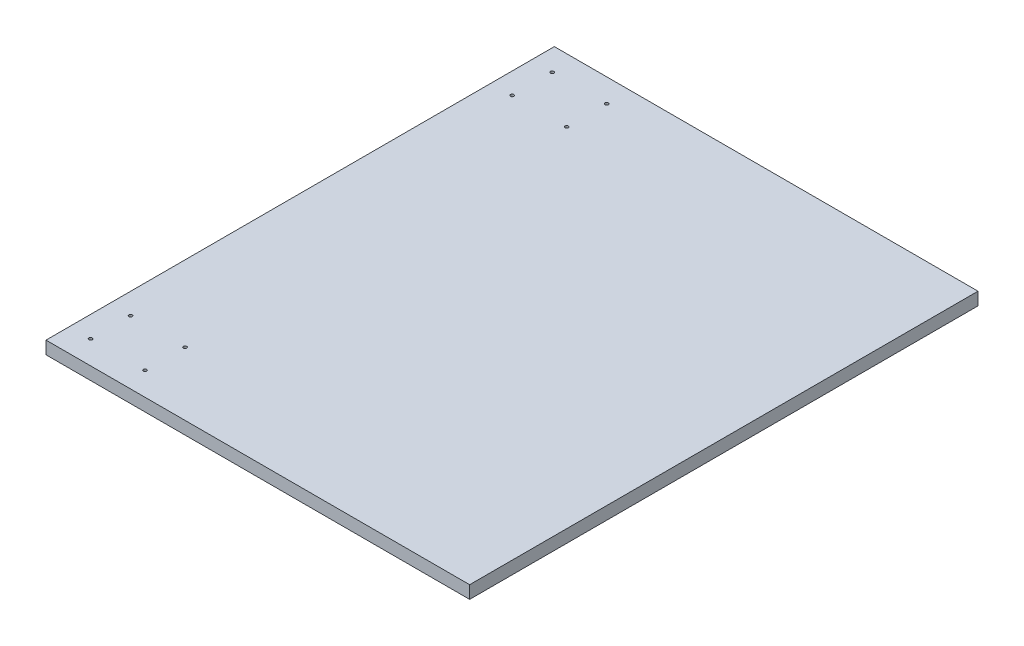
from build123d import *

# Parameters (mm, degrees)
SKETCH1_W           = 381
SKETCH1_H           = 457.2
BOSS_EXTRUDE1_DEPTH = 11.4554
SKETCH3_R           = 1.5
CUT_EXTRUDE1_DEPTH  = 12.4554


with BuildPart() as part:
    # Sketch1 → Boss-Extrude1 (new body)
    with BuildSketch(Plane(origin=(0, 0, 0), x_dir=(1, 0, 0), z_dir=(0, 1, 0))):
        Rectangle(SKETCH1_W, SKETCH1_H)
    extrude(amount=BOSS_EXTRUDE1_DEPTH)

    # Sketch3 → Cut-Extrude1 (cut, through all)
    with BuildSketch(Plane(origin=(0, 11.4554, 0), x_dir=(1, 0, 0), z_dir=(0, 1, 0))):
        with Locations((-122.45, 207.6)):
            Circle(SKETCH3_R)
        with Locations((-171.45, 207.6)):
            Circle(SKETCH3_R)
        with Locations((-171.45, 171.6)):
            Circle(SKETCH3_R)
        with Locations((-122.45, 171.6)):
            Circle(SKETCH3_R)
        with Locations((-122.45, -171.6)):
            Circle(SKETCH3_R)
        with Locations((-171.45, -171.6)):
            Circle(SKETCH3_R)
        with Locations((-171.45, -207.6)):
            Circle(SKETCH3_R)
        with Locations((-122.45, -207.6)):
            Circle(SKETCH3_R)
    extrude(amount=-CUT_EXTRUDE1_DEPTH, mode=Mode.SUBTRACT)


solid = part.part
